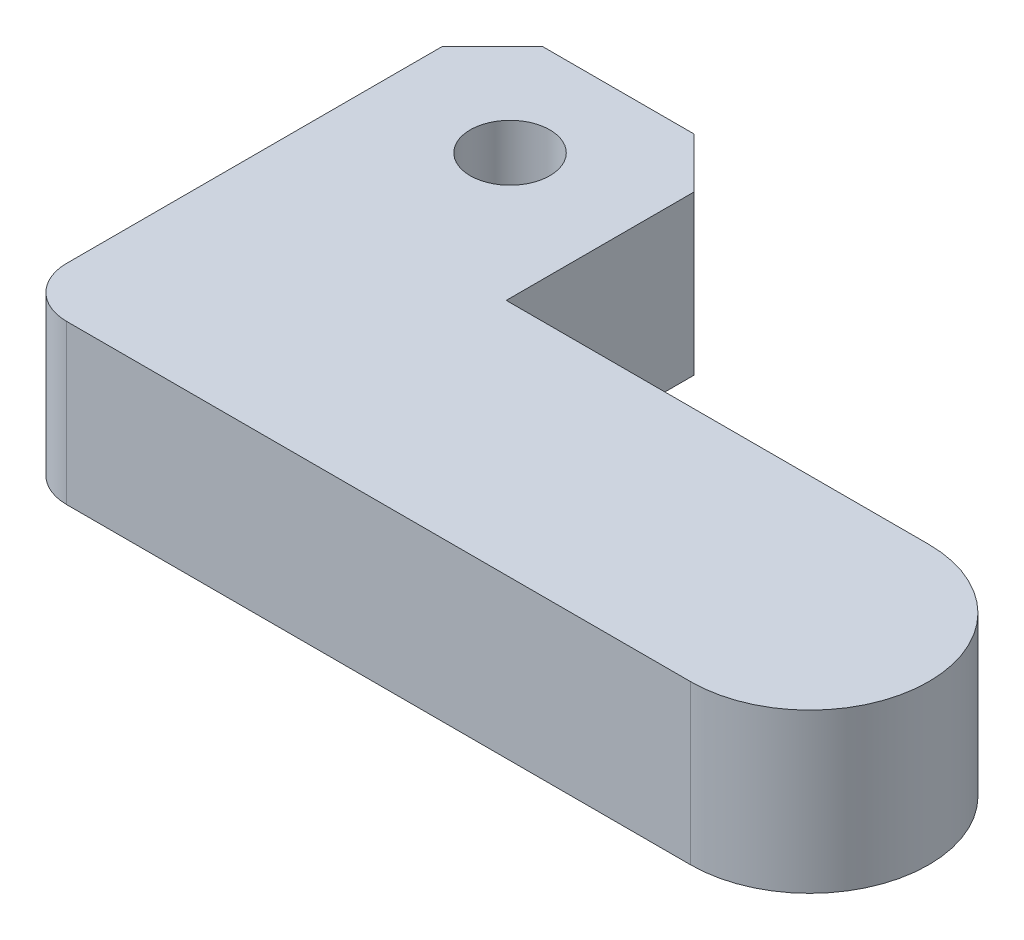
from build123d import *

# Parameters (mm, degrees)
SKETCH1_R           = 2.50825
BOSS_EXTRUDE1_DEPTH = 10
FILLET1_R           = 3.175
CHAMFER1_SIZE       = 3.175


with BuildPart() as part:
    # Sketch1 → Boss-Extrude1 (new body)
    with BuildSketch(Plane(origin=(0, 0, 0), x_dir=(1, 0, 0), z_dir=(0, 1, 0))):
        with BuildLine():
            Line((0, 30), (0, 0))
            Line((0, 0), (42.5, 0))
            ThreePointArc((42.5, 0), (50, 7.5), (42.5, 15))
            Line((42.5, 15), (15.875, 15))
            Line((15.875, 15), (15.875, 30))
            Line((15.875, 30), (0, 30))
        make_face()
        with Locations((7.9375, 23.175)):
            Circle(SKETCH1_R, mode=Mode.SUBTRACT)
    extrude(amount=BOSS_EXTRUDE1_DEPTH)

    # Fillet1
    fillet1_edges = [part.edges().sort_by_distance(p)[0] for p in [
        (0, 5, 0),
    ]]
    fillet(fillet1_edges, radius=FILLET1_R)

    # Chamfer1
    chamfer1_edges = [part.edges().sort_by_distance(p)[0] for p in [
        (15.875, 5, -30),
        (0, 5, -30),
    ]]
    chamfer(chamfer1_edges, length=CHAMFER1_SIZE)


solid = part.part
